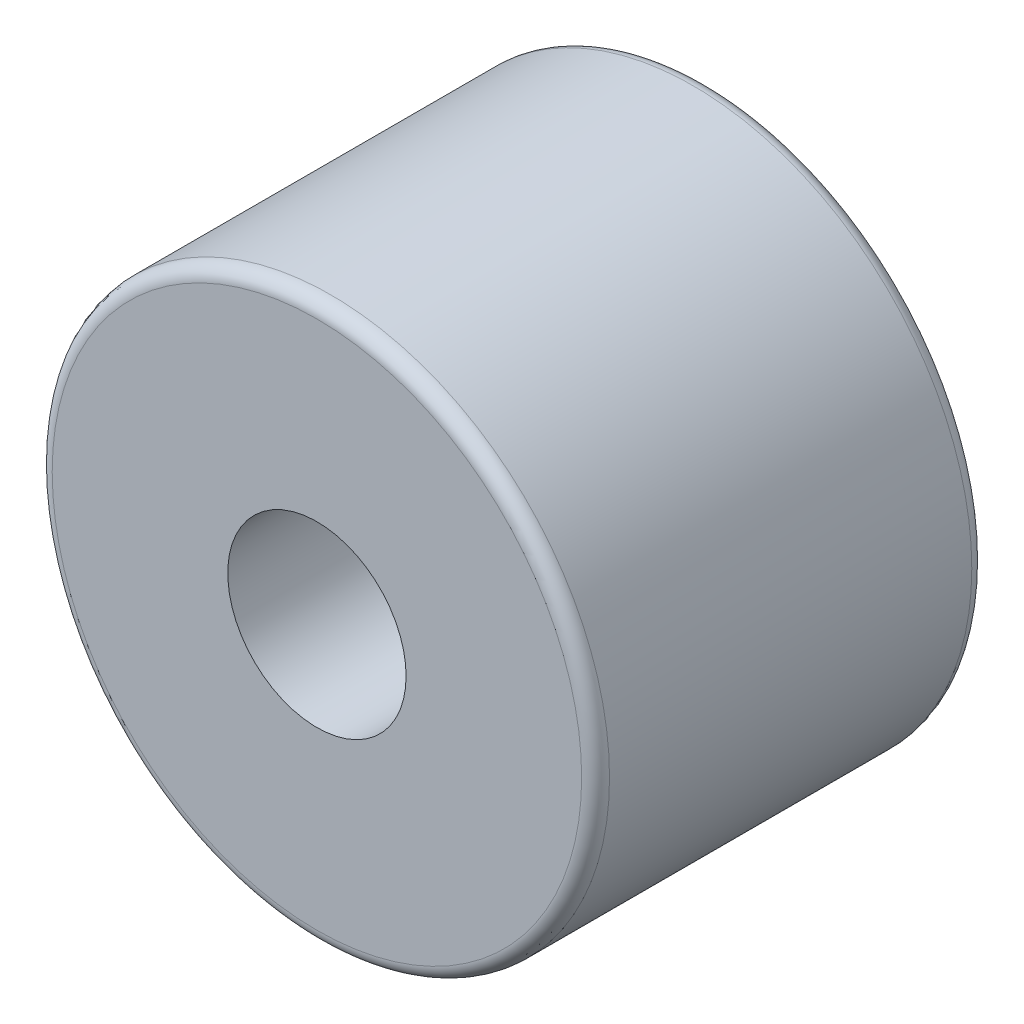
from build123d import *

# Parameters (mm, degrees)
ESQUISSE1_R        = 5
ESQUISSE1_R_2      = 1.6
BOSS_EXTRU_1_DEPTH = 7
CONG_1_R           = 0.25
CONG_2_R           = 0.25


with BuildPart() as part:
    # Esquisse1 → Boss.-Extru.1 (new body)
    with BuildSketch(Plane.XY):
        Circle(ESQUISSE1_R)
        Circle(ESQUISSE1_R_2, mode=Mode.SUBTRACT)
    extrude(amount=BOSS_EXTRU_1_DEPTH)

    # Congé1
    cong_1_edges = [part.edges().sort_by_distance(p)[0] for p in [
        (-5, 0, 7),
    ]]
    fillet(cong_1_edges, radius=CONG_1_R)

    # Congé2
    cong_2_edges = [part.edges().sort_by_distance(p)[0] for p in [
        (-5, 0, 0),
    ]]
    fillet(cong_2_edges, radius=CONG_2_R)


solid = part.part
